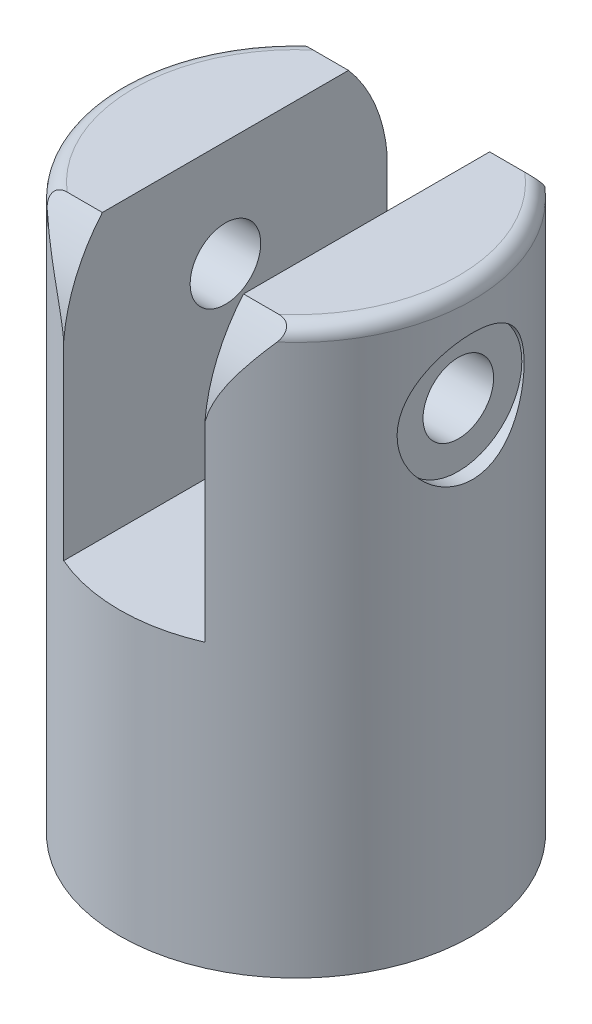
from build123d import *

# Parameters (mm, degrees)
SKETCH1_R               = 125
BOSS_EXTRUDE1_DEPTH     = 400
SKETCH2_W               = 100
SKETCH2_H               = 250
CUT_EXTRUDE1_DEPTH      = 200
SKETCH4_R               = 50
CUT_EXTRUDE3_DEPTH      = 60
SKETCH7_R               = 25
CUT_EXTRUDE6_DEPTH      = 176
CUT_EXTRUDE6_DEPTH_BACK = 76
FILLET2_R               = 10
SKETCH8_R               = 45
SKETCH8_R_2             = 25
CUT_EXTRUDE7_DEPTH      = 10
SKETCH10_R              = 45
SKETCH10_R_2            = 25
CUT_EXTRUDE8_DEPTH      = 10


with BuildPart() as part:
    # Sketch1 → Boss-Extrude1 (new body)
    with BuildSketch(Plane(origin=(0, 0, 0), x_dir=(1, 0, 0), z_dir=(0, 1, 0))):
        Circle(SKETCH1_R)
    extrude(amount=BOSS_EXTRUDE1_DEPTH)

    # Sketch2 → Cut-Extrude1 (cut)
    with BuildSketch(Plane(origin=(0, 400, 0), x_dir=(1, 0, 0), z_dir=(0, 1, 0))):
        Rectangle(SKETCH2_W, SKETCH2_H)
    extrude(amount=-CUT_EXTRUDE1_DEPTH, mode=Mode.SUBTRACT)

    # Sketch4 → Cut-Extrude3 (cut)
    with BuildSketch(Plane.XZ):
        Circle(SKETCH4_R)
    extrude(amount=-CUT_EXTRUDE3_DEPTH, mode=Mode.SUBTRACT)

    # Sketch7 → Cut-Extrude6 (cut, two sides)
    with BuildSketch(Plane(origin=(-50, 0, 0), x_dir=(0, 0, -1), z_dir=(1, 0, 0))) as cut_extrude6_sk:
        with BuildLine():
            Line((-87.177978871, 400), (-114.564392374, 400))
            Line((-114.564392374, 400), (-114.564392374, 335))
            ThreePointArc((-114.564392374, 335), (-105.977573518, 369.651471545), (-87.177978871, 400))
        make_face()
        with BuildLine():
            ThreePointArc((87.177978871, 400), (105.977573518, 369.651471545), (114.564392374, 335))
            Line((114.564392374, 335), (114.564392374, 400))
            Line((114.564392374, 400), (87.177978871, 400))
        make_face()
        with Locations((0, 325)):
            Circle(SKETCH7_R)
    extrude(amount=CUT_EXTRUDE6_DEPTH, mode=Mode.SUBTRACT)
    extrude(cut_extrude6_sk.sketch, amount=-CUT_EXTRUDE6_DEPTH_BACK, mode=Mode.SUBTRACT)

    # Fillet2
    fillet2_edges = [part.edges().sort_by_distance(p)[0] for p in [
        (115.807589436, 400, 47.048934409),
        (-125, 400, 0),
    ]]
    fillet(fillet2_edges, radius=FILLET2_R)

    # Sketch8 → Cut-Extrude7 (cut)
    with BuildSketch(Plane(origin=(-125, 0, 0), x_dir=(0, 0, -1), z_dir=(1, 0, 0))):
        with Locations((0, 325)):
            Circle(SKETCH8_R)
        with Locations((0, 325)):
            Circle(SKETCH8_R_2, mode=Mode.SUBTRACT)
    extrude(amount=CUT_EXTRUDE7_DEPTH, mode=Mode.SUBTRACT)

    # Sketch10 → Cut-Extrude8 (cut)
    with BuildSketch(Plane.ZY.offset(-125)):
        with Locations((0, 325)):
            Circle(SKETCH10_R)
        with Locations((0, 325)):
            Circle(SKETCH10_R_2, mode=Mode.SUBTRACT)
    extrude(amount=CUT_EXTRUDE8_DEPTH, mode=Mode.SUBTRACT)


solid = part.part
